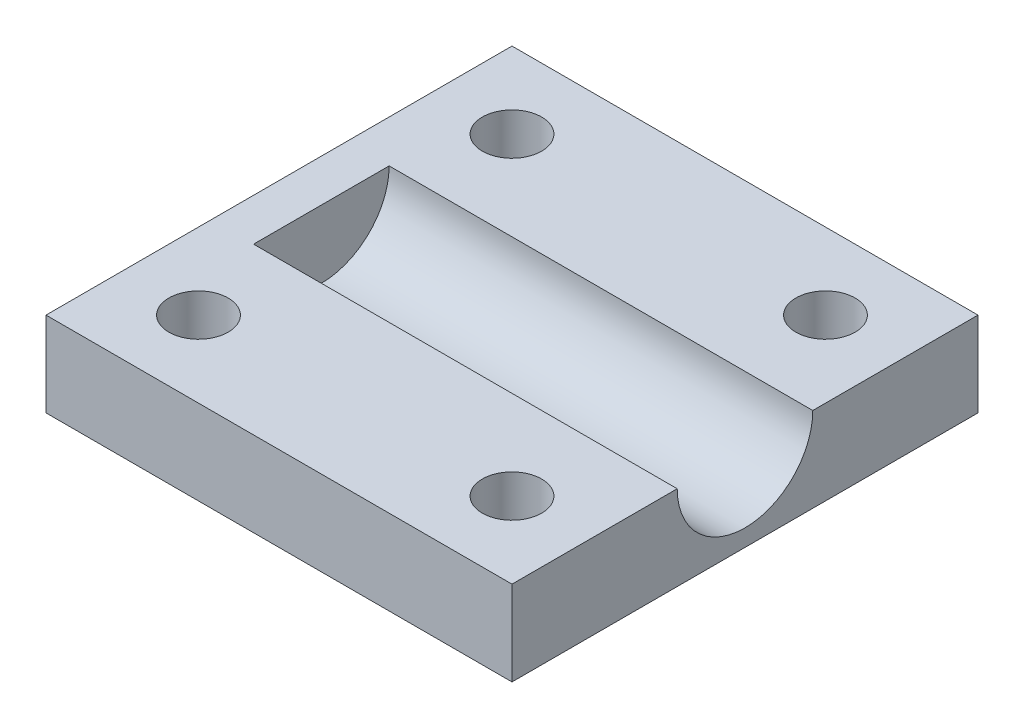
from build123d import *

# Parameters (mm, degrees)
SKETCH1_W           = 55
SKETCH1_H           = 55
BOSS_EXTRUDE1_DEPTH = 10
SKETCH2_R           = 8
CUT_EXTRUDE1_DEPTH  = 50
SKETCH3_R           = 3.5
CUT_EXTRUDE2_DEPTH  = 5


with BuildPart() as part:
    # Sketch1 → Boss-Extrude1 (new body)
    with BuildSketch(Plane(origin=(0, 0, 0), x_dir=(1, 0, 0), z_dir=(0, 1, 0))):
        Rectangle(SKETCH1_W, SKETCH1_H)
    extrude(amount=BOSS_EXTRUDE1_DEPTH)

    # Sketch2 → Cut-Extrude1 (cut)
    with BuildSketch(Plane(origin=(27.5, 0, 0), x_dir=(0, 0, -1), z_dir=(1, 0, 0))):
        with Locations((0, 10)):
            Circle(SKETCH2_R)
    extrude(amount=-CUT_EXTRUDE1_DEPTH, mode=Mode.SUBTRACT)

    # Sketch3 → Cut-Extrude2 (cut)
    with BuildSketch(Plane(origin=(0, 10, 0), x_dir=(1, 0, 0), z_dir=(0, 1, 0))):
        with Locations((-18.5, 18.5)):
            Circle(SKETCH3_R)
        with Locations((18.5, 18.5)):
            Circle(SKETCH3_R)
        with Locations((-18.5, -18.5)):
            Circle(SKETCH3_R)
        with Locations((18.5, -18.5)):
            Circle(SKETCH3_R)
    extrude(amount=-CUT_EXTRUDE2_DEPTH, mode=Mode.SUBTRACT)


solid = part.part
